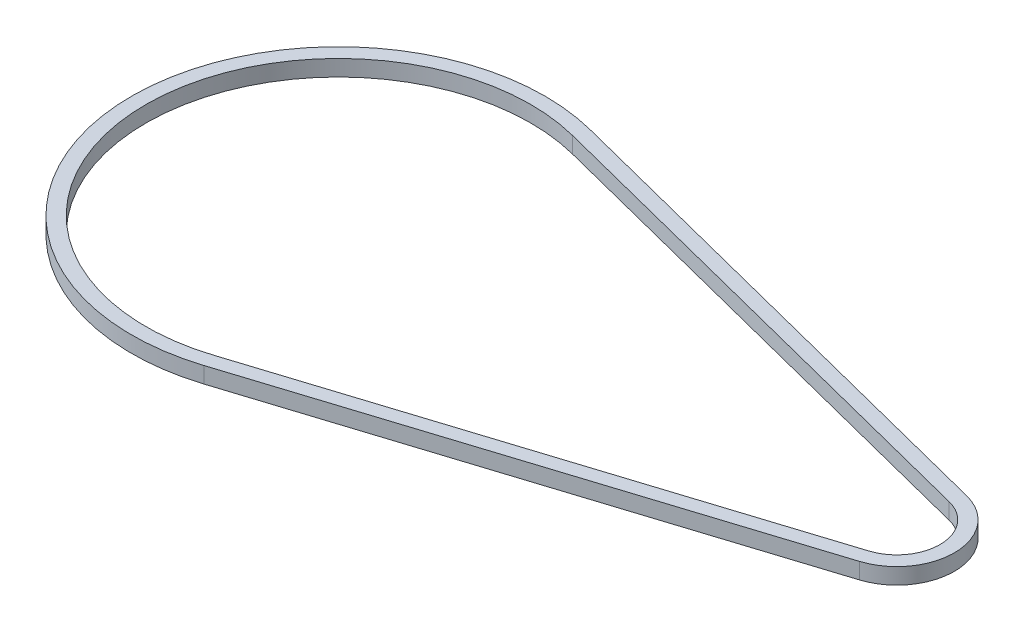
from build123d import *

# Parameters (mm, degrees)
BOSS_EXTRUDE1_DEPTH = 8.4


with BuildPart() as part:
    # Sketch1 → Boss-Extrude1 (new body)
    with BuildSketch(Plane(origin=(0, 0, 0), x_dir=(1, 0, 0), z_dir=(0, 1, 0))):
        with BuildLine():
            Line((-166.082554014, 101.412223314), (98.0831936, 34.083436717))
            ThreePointArc((98.0831936, 34.083436717), (120.661149964, 5.886177217), (99.762556875, -23.577331804))
            Line((99.762556875, -23.577331804), (-160.036846225, -106.166543363))
            ThreePointArc((-160.036846225, -106.166543363), (-300.710357378, -6.386219641), (-166.082554014, 101.412223314))
        make_face()
        with BuildLine():
            Line((-162.309019004, -99.019010162), (97.490384096, -16.429798603))
            ThreePointArc((97.490384096, -16.429798603), (113.164328913, 5.667833163), (96.23086164, 26.815777788))
            Line((96.23086164, 26.815777788), (-167.934885974, 94.144564385))
            ThreePointArc((-167.934885974, 94.144564385), (-293.213536327, -6.167875587), (-162.309019004, -99.019010162))
        make_face(mode=Mode.SUBTRACT)
    extrude(amount=BOSS_EXTRUDE1_DEPTH)


solid = part.part
